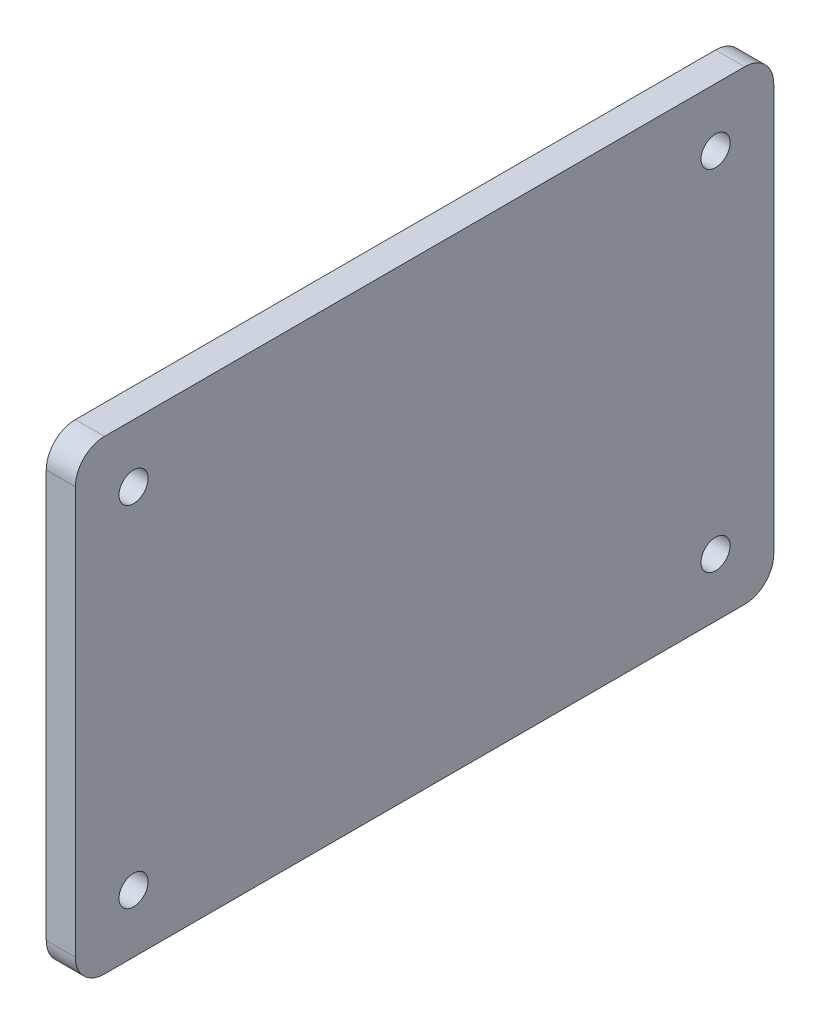
from build123d import *

# Parameters (mm, degrees)
SKETCH1_W                   = 152.4
SKETCH1_H                   = 101.6
BOSS_EXTRUDE1_DEPTH         = 6.35
F_1_4_0_25_DIAMETER_HOLE1_D = 6.35
LPATTERN1_COUNT             = 2
LPATTERN1_PITCH             = 76.2
LPATTERN1_COUNT_DIR2        = 2
LPATTERN1_PITCH_DIR2        = 127
FILLET1_R                   = 6.35


with BuildPart() as part:
    # Sketch1 → Boss-Extrude1 (new body)
    with BuildSketch(Plane.ZY.offset(323.85)):
        with Locations((-342.9, 69.85)):
            Rectangle(SKETCH1_W, SKETCH1_H)
    extrude(amount=BOSS_EXTRUDE1_DEPTH)

    # 1/4 (0.25) Diameter Hole1 (through all)
    with Locations(Plane.ZY.offset(330.2)):
        with Locations((-406.4, 31.75)):
            f_1_4_0_25_diameter_hole1 = Hole(F_1_4_0_25_DIAMETER_HOLE1_D / 2)

    # LPattern1: 1_4 _0.25_ Diameter Hole1 2 × 2
    with Locations(*[(0, i * LPATTERN1_PITCH, j * LPATTERN1_PITCH_DIR2) for i in range(LPATTERN1_COUNT) for j in range(LPATTERN1_COUNT_DIR2) if (i, j) != (0, 0)]):
        add(f_1_4_0_25_diameter_hole1, mode=Mode.SUBTRACT)

    # Fillet1
    fillet1_edges = [part.edges().sort_by_distance(p)[0] for p in [
        (-327.025, 120.65, -419.1),
        (-327.025, 120.65, -266.7),
        (-327.025, 19.05, -266.7),
        (-327.025, 19.05, -419.1),
    ]]
    fillet(fillet1_edges, radius=FILLET1_R)


solid = part.part
